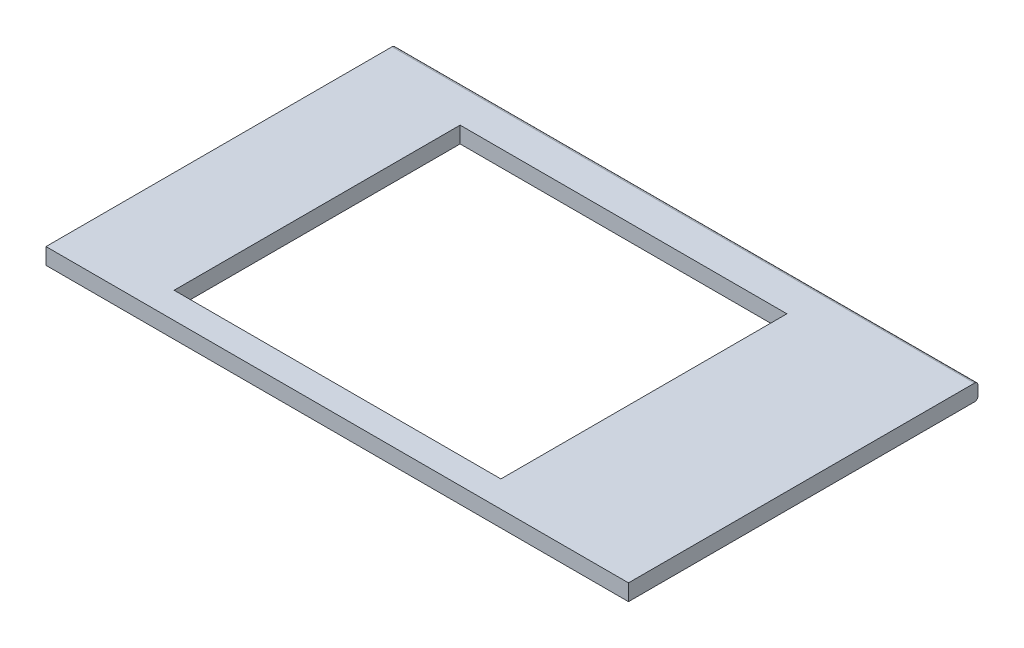
from build123d import *

# Parameters (mm, degrees)
EXTRUDE_1_DEPTH     = 1000
SKETCH_3_W          = 561
SKETCH_3_H          = 491
CUT_EXTRUDE_1_DEPTH = 29


with BuildPart() as part:
    # Эскиз2 → Бобышка-Вытянуть1 (new body)
    with BuildSketch(Plane(origin=(0, 0, 0), x_dir=(0, 0, -1), z_dir=(1, 0, 0))):
        with BuildLine():
            Line((0, 0), (594, 0))
            ThreePointArc((594, 0), (598.242640687, 1.757359313), (600, 6))
            Line((600, 6), (600, 22))
            ThreePointArc((600, 22), (598.242640687, 26.242640687), (594, 28))
            Line((594, 28), (0, 28))
            Line((0, 28), (0, 0))
        make_face()
    extrude(amount=EXTRUDE_1_DEPTH)

    # Эскиз3 → Вырез-Вытянуть1 (cut, through all)
    with BuildSketch(Plane(origin=(0, 28, 0), x_dir=(1, 0, 0), z_dir=(0, 1, 0))):
        with Locations((455.438358963, 290.5)):
            Rectangle(SKETCH_3_W, SKETCH_3_H)
    extrude(amount=-CUT_EXTRUDE_1_DEPTH, mode=Mode.SUBTRACT)


solid = part.part
